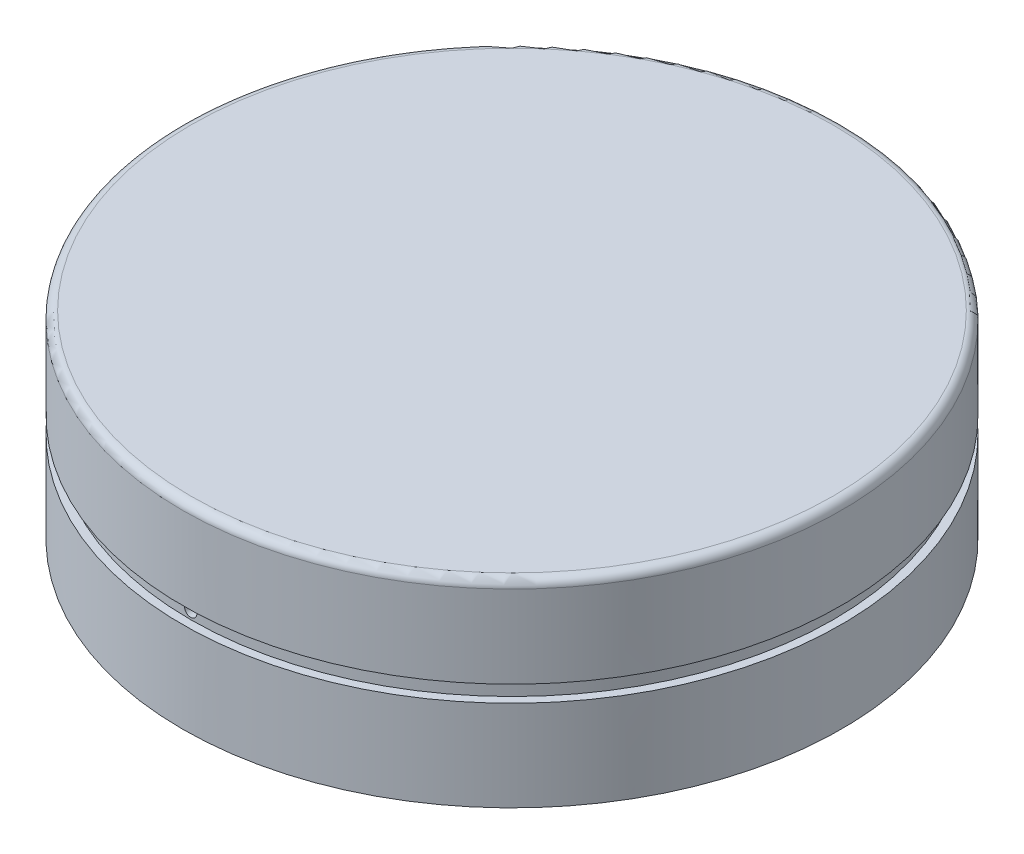
from build123d import *

# Parameters (mm, degrees)
SKETCH2_R               = 20
BOSS_EXTRUDE1_DEPTH     = 6
SKETCH3_R               = 19
CUT_EXTRUDE1_DEPTH      = 11
FILLET1_R               = 0.5
SKETCH5_W               = 0.5
SKETCH5_H               = 1
SKETCH6_R               = 0.375
CUT_EXTRUDE2_DEPTH      = 21.0000001
CUT_EXTRUDE2_DEPTH_BACK = 21.0000001


with BuildPart() as part:
    # Sketch2 → Boss-Extrude1 (new body, symmetric)
    with BuildSketch(Plane(origin=(0, 0, 0), x_dir=(1, 0, 0), z_dir=(0, 1, 0))):
        Circle(SKETCH2_R)
    extrude(amount=BOSS_EXTRUDE1_DEPTH, both=True)

    # Sketch3 → Cut-Extrude1 (cut)
    with BuildSketch(Plane.XZ.offset(6)):
        Circle(SKETCH3_R)
    extrude(amount=-CUT_EXTRUDE1_DEPTH, mode=Mode.SUBTRACT)

    # Fillet1
    fillet1_edges = [part.edges().sort_by_distance(p)[0] for p in [
        (-20, 6, 0),
    ]]
    fillet(fillet1_edges, radius=FILLET1_R)

    # Sketch5 → Cut-Revolve1 (revolve, cut)
    with BuildSketch(Plane.XY):
        with Locations((19.75, 0)):
            Rectangle(SKETCH5_W, SKETCH5_H)
    revolve(axis=Axis((0, 0, 0), (0, 1, 0)), mode=Mode.SUBTRACT)

    # Sketch6 → Cut-Extrude2 (cut, two sides)
    with BuildSketch(Plane.XY) as cut_extrude2_sk:
        Circle(SKETCH6_R)
    extrude(amount=CUT_EXTRUDE2_DEPTH, mode=Mode.SUBTRACT)
    extrude(cut_extrude2_sk.sketch, amount=-CUT_EXTRUDE2_DEPTH_BACK, mode=Mode.SUBTRACT)

    # Sketch7 → Revolve1 (revolve)
    with BuildSketch(Plane.XY):
        Polygon((5.9, 5), (5.9, 1), (6.9, 1), (7.9, 5), align=None)
    revolve(axis=Axis((0, 5, 0), (0, -1, 0)))


solid = part.part
